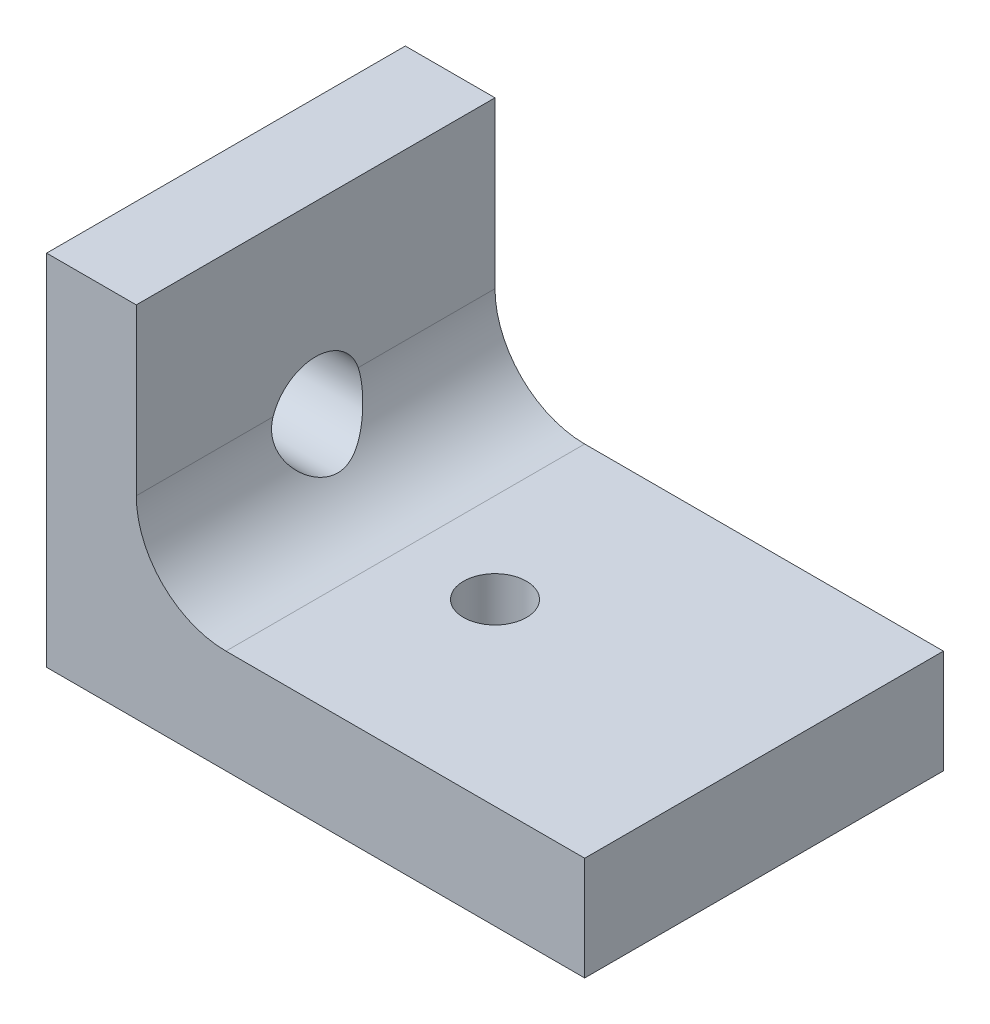
from build123d import *

# Parameters (mm, degrees)
BOSS_EXTRUDE1_DEPTH = 20
SKETCH2_R           = 1.755
CUT_EXTRUDE1_DEPTH  = 20
SKETCH3_R           = 2.5
CUT_EXTRUDE2_DEPTH  = 20


with BuildPart() as part:
    # Sketch1 → Boss-Extrude1 (new body)
    with BuildSketch(Plane.XY):
        with BuildLine():
            Line((0, 20), (0, 0))
            Line((0, 0), (30, 0))
            Line((30, 0), (30, 5.78313253))
            Line((30, 5.78313253), (10, 5.78313253))
            ThreePointArc((10, 5.78313253), (6.464466094, 7.247598624), (5, 10.78313253))
            Line((5, 10.78313253), (5, 20))
            Line((5, 20), (0, 20))
        make_face()
    extrude(amount=BOSS_EXTRUDE1_DEPTH)

    # Sketch2 → Cut-Extrude1 (cut)
    with BuildSketch(Plane.XZ):
        with Locations((15, 10)):
            Circle(SKETCH2_R)
    extrude(amount=-CUT_EXTRUDE1_DEPTH, mode=Mode.SUBTRACT)

    # Sketch3 → Cut-Extrude2 (cut)
    with BuildSketch(Plane.ZY):
        with Locations((10, 10)):
            Circle(SKETCH3_R)
    extrude(amount=-CUT_EXTRUDE2_DEPTH, mode=Mode.SUBTRACT)


solid = part.part
